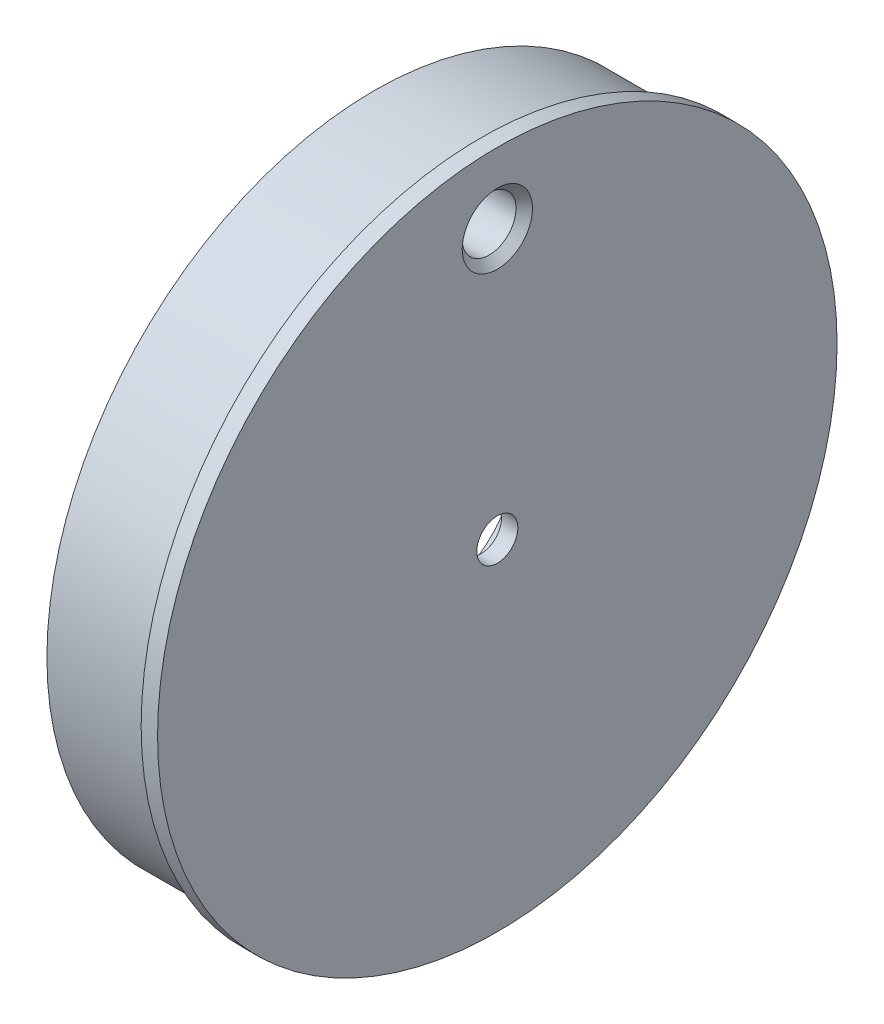
from build123d import *


with BuildPart() as part:
    # Sketch1 → Revolve1 (revolve)
    with BuildSketch(Plane.XY, mode=Mode.PRIVATE) as revolve1_sk:
        with BuildLine():
            Line((0, 1.5875), (0, 26.289))
            Line((0, 26.289), (-1.27, 26.289))
            Line((-1.27, 26.289), (-1.27, 25.3238))
            Line((-1.27, 25.3238), (-9.525, 25.3238))
            Line((-9.525, 25.3238), (-9.525, 17.1958))
            Line((-9.525, 17.1958), (-6.223, 17.1958))
            ThreePointArc((-6.223, 17.1958), (-5.324974388, 16.823825612), (-4.953, 15.9258))
            Line((-4.953, 15.9258), (-4.953, 6.35))
            Line((-4.953, 6.35), (-2.54, 6.35))
            ThreePointArc((-2.54, 6.35), (-1.641974388, 5.978025612), (-1.27, 5.08))
            Line((-1.27, 5.08), (-1.27, 1.5875))
            Line((-1.27, 1.5875), (0, 1.5875))
        make_face()
    revolve(revolve1_sk.sketch.rotate(Axis((0, 0, 0), (-1, 0, 0)), 90), axis=Axis((0, 0, 0), (-1, 0, 0)))  # turned: the seam where the file's is

    # Sketch3 → #8-32 Tapped Hole1 (revolve, cut)
    with BuildSketch(Plane(origin=(-9.525, 20.828, 0), x_dir=(0, 0, 1), z_dir=(0, 1, 0))):
        Polygon((0, 0), (0, 9.525), (2.7178, 9.525), (2.0828, 8.89), (2.0828, 0.635), (2.7178, 0), align=None)
    revolve(axis=Axis((-15.875, 20.828, 0), (1, 0, 0)), mode=Mode.SUBTRACT)


solid = part.part
